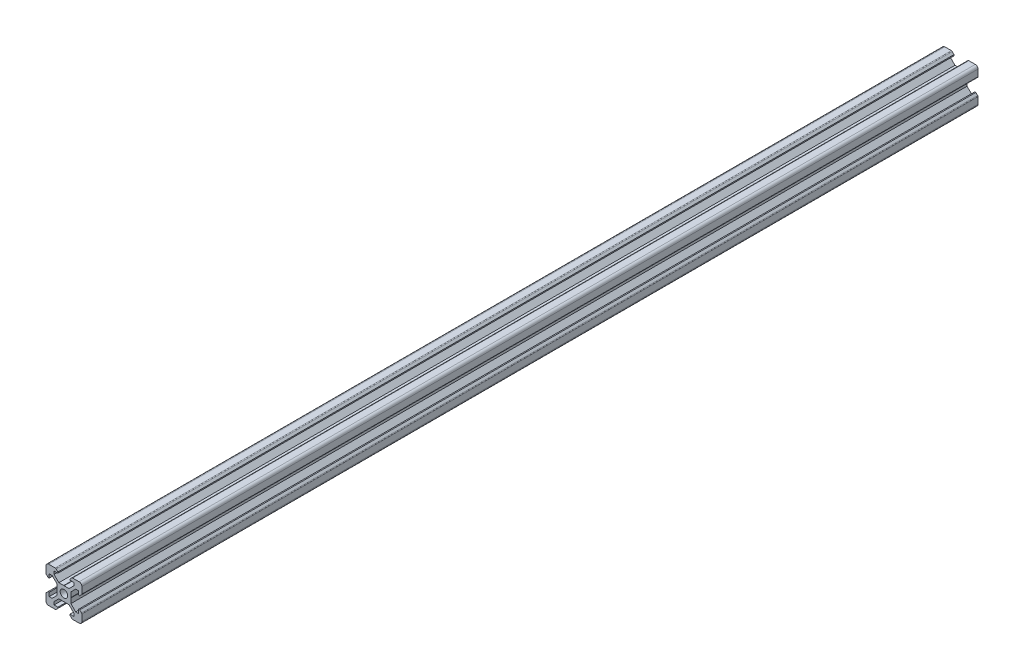
from build123d import *

# Parameters (mm, degrees)
SKETCH1_R           = 2.1
BOSS_EXTRUDE1_DEPTH = 500


with BuildPart() as part:
    # Sketch1 → Boss-Extrude1 (new body)
    with BuildSketch(Plane.XY):
        with BuildLine():
            Line((-8.5, 10), (-4.862792737, 10))
            ThreePointArc((-4.862792737, 10), (-4.598292737, 9.947387679), (-4.374060464, 9.797560464))
            Line((-4.374060464, 9.797560464), (-3.3865, 8.81))
            Line((-3.3865, 8.81), (-3.3865, 8.2))
            Line((-3.3865, 8.2), (-5.5, 8.2))
            Line((-5.5, 8.2), (-5.5, 6.561))
            Line((-5.5, 6.561), (-2.8395, 3.9005))
            Line((-2.8395, 3.9005), (-0.1, 3.9005))
            Line((-0.1, 3.9005), (0, 3.8005))
            Line((0, 3.8005), (0.1, 3.9005))
            Line((0.1, 3.9005), (2.8395, 3.9005))
            Line((2.8395, 3.9005), (5.5, 6.561))
            Line((5.5, 6.561), (5.5, 8.2))
            Line((5.5, 8.2), (3.3865, 8.2))
            Line((3.3865, 8.2), (3.3865, 8.81))
            Line((3.3865, 8.81), (4.374060464, 9.797560464))
            ThreePointArc((4.374060464, 9.797560464), (4.598292737, 9.947387679), (4.862792737, 10))
            Line((4.862792737, 10), (8.5, 10))
            ThreePointArc((8.5, 10), (9.560660172, 9.560660172), (10, 8.5))
            Line((10, 8.5), (10, 4.862792737))
            ThreePointArc((10, 4.862792737), (9.947387679, 4.598292737), (9.797560464, 4.374060464))
            Line((9.797560464, 4.374060464), (8.81, 3.3865))
            Line((8.81, 3.3865), (8.2, 3.3865))
            Line((8.2, 3.3865), (8.2, 5.5))
            Line((8.2, 5.5), (6.561, 5.5))
            Line((6.561, 5.5), (3.9005, 2.8395))
            Line((3.9005, 2.8395), (3.9005, 0.1))
            Line((3.9005, 0.1), (3.8005, 0))
            Line((3.8005, 0), (3.9005, -0.1))
            Line((3.9005, -0.1), (3.9005, -2.8395))
            Line((3.9005, -2.8395), (6.561, -5.5))
            Line((6.561, -5.5), (8.2, -5.5))
            Line((8.2, -5.5), (8.2, -3.3865))
            Line((8.2, -3.3865), (8.81, -3.3865))
            Line((8.81, -3.3865), (9.797560464, -4.374060464))
            ThreePointArc((9.797560464, -4.374060464), (9.947387679, -4.598292737), (10, -4.862792737))
            Line((10, -4.862792737), (10, -8.5))
            ThreePointArc((10, -8.5), (9.560660172, -9.560660172), (8.5, -10))
            Line((8.5, -10), (4.862792737, -10))
            ThreePointArc((4.862792737, -10), (4.598292737, -9.947387679), (4.374060464, -9.797560464))
            Line((4.374060464, -9.797560464), (3.3865, -8.81))
            Line((3.3865, -8.81), (3.3865, -8.2))
            Line((3.3865, -8.2), (5.5, -8.2))
            Line((5.5, -8.2), (5.5, -6.561))
            Line((5.5, -6.561), (2.8395, -3.9005))
            Line((2.8395, -3.9005), (0.1, -3.9005))
            Line((0.1, -3.9005), (0, -3.8005))
            Line((0, -3.8005), (-0.1, -3.9005))
            Line((-0.1, -3.9005), (-2.8395, -3.9005))
            Line((-2.8395, -3.9005), (-5.5, -6.561))
            Line((-5.5, -6.561), (-5.5, -8.2))
            Line((-5.5, -8.2), (-3.3865, -8.2))
            Line((-3.3865, -8.2), (-3.3865, -8.81))
            Line((-3.3865, -8.81), (-4.374060464, -9.797560464))
            ThreePointArc((-4.374060464, -9.797560464), (-4.598292737, -9.947387679), (-4.862792737, -10))
            Line((-4.862792737, -10), (-8.5, -10))
            ThreePointArc((-8.5, -10), (-9.560660172, -9.560660172), (-10, -8.5))
            Line((-10, -8.5), (-10, -4.862792737))
            ThreePointArc((-10, -4.862792737), (-9.947387679, -4.598292737), (-9.797560464, -4.374060464))
            Line((-9.797560464, -4.374060464), (-8.81, -3.3865))
            Line((-8.81, -3.3865), (-8.2, -3.3865))
            Line((-8.2, -3.3865), (-8.2, -5.5))
            Line((-8.2, -5.5), (-6.561, -5.5))
            Line((-6.561, -5.5), (-3.9005, -2.8395))
            Line((-3.9005, -2.8395), (-3.9005, -0.1))
            Line((-3.9005, -0.1), (-3.8005, 0))
            Line((-3.8005, 0), (-3.9005, 0.1))
            Line((-3.9005, 0.1), (-3.9005, 2.8395))
            Line((-3.9005, 2.8395), (-6.561, 5.5))
            Line((-6.561, 5.5), (-8.2, 5.5))
            Line((-8.2, 5.5), (-8.2, 3.3865))
            Line((-8.2, 3.3865), (-8.81, 3.3865))
            Line((-8.81, 3.3865), (-9.797560464, 4.374060464))
            ThreePointArc((-9.797560464, 4.374060464), (-9.947387679, 4.598292737), (-10, 4.862792737))
            Line((-10, 4.862792737), (-10, 8.5))
            ThreePointArc((-10, 8.5), (-9.560660172, 9.560660172), (-8.5, 10))
        make_face()
        Circle(SKETCH1_R, mode=Mode.SUBTRACT)
    extrude(amount=BOSS_EXTRUDE1_DEPTH)


solid = part.part
